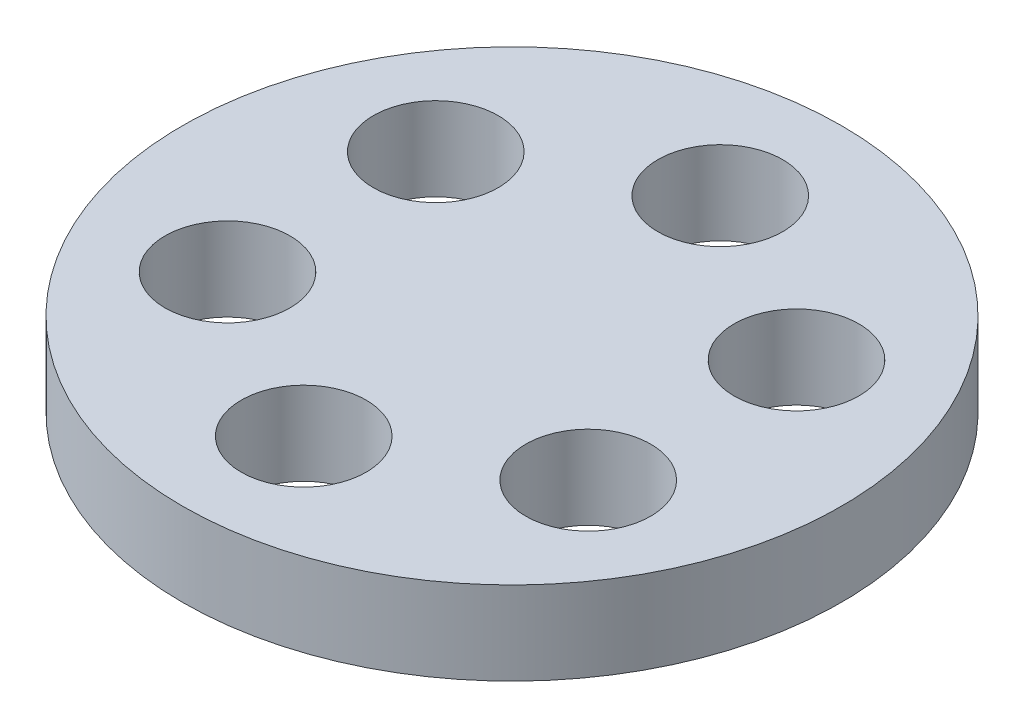
from build123d import *

# Parameters (mm, degrees)
SKETCH3_R           = 50.2412
SKETCH3_R_2         = 9.525
BOSS_EXTRUDE1_DEPTH = 12.7


with BuildPart() as part:
    # Sketch3 → Boss-Extrude1 (new body)
    with BuildSketch(Plane(origin=(0, 0, 0), x_dir=(1, 0, 0), z_dir=(0, 1, 0))):
        Circle(SKETCH3_R)
        with Locations((0, 31.75)):
            Circle(SKETCH3_R_2, mode=Mode.SUBTRACT)
        with Locations((27.49630657, 15.875)):
            Circle(SKETCH3_R_2, mode=Mode.SUBTRACT)
        with Locations((27.49630657, -15.875)):
            Circle(SKETCH3_R_2, mode=Mode.SUBTRACT)
        with Locations((0, -31.75)):
            Circle(SKETCH3_R_2, mode=Mode.SUBTRACT)
        with Locations((-27.49630657, -15.875)):
            Circle(SKETCH3_R_2, mode=Mode.SUBTRACT)
        with Locations((-27.49630657, 15.875)):
            Circle(SKETCH3_R_2, mode=Mode.SUBTRACT)
    extrude(amount=BOSS_EXTRUDE1_DEPTH)


solid = part.part
